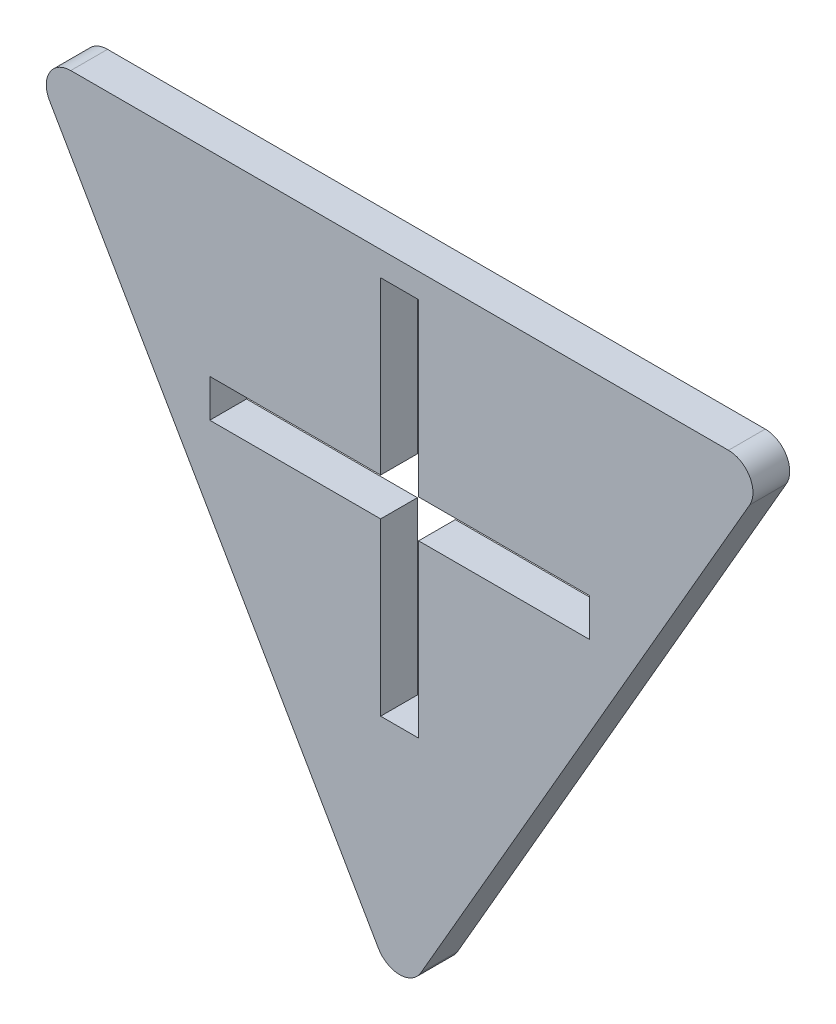
from build123d import *

# Parameters (mm, degrees)
BOSS_EXTRUDE1_DEPTH = 1.5


with BuildPart() as part:
    # Sketch1 → Boss-Extrude1 (new body, symmetric)
    with BuildSketch(Plane.XY):
        with BuildLine():
            ThreePointArc((28.578838325, 14.5), (28.578838325, 16.5), (26.846787517, 17.5))
            Line((26.846787517, 17.5), (-26.846787517, 17.5))
            ThreePointArc((-26.846787517, 17.5), (-28.578838325, 16.5), (-28.578838325, 14.5))
            Line((-28.578838325, 14.5), (-1.732050808, -32))
            ThreePointArc((-1.732050808, -32), (0, -33), (1.732050808, -32))
            Line((1.732050808, -32), (28.578838325, 14.5))
        make_face()
        Polygon((-1.55, 1.55), (-1.55, 15.5), (1.55, 15.5), (1.55, 1.55), (15.5, 1.55), (15.5, -1.55), (1.55, -1.55), (1.55, -15.5), (-1.55, -15.5), (-1.55, -1.55), (-15.5, -1.55), (-15.5, 1.55), align=None, mode=Mode.SUBTRACT)
    extrude(amount=BOSS_EXTRUDE1_DEPTH, both=True)


solid = part.part
